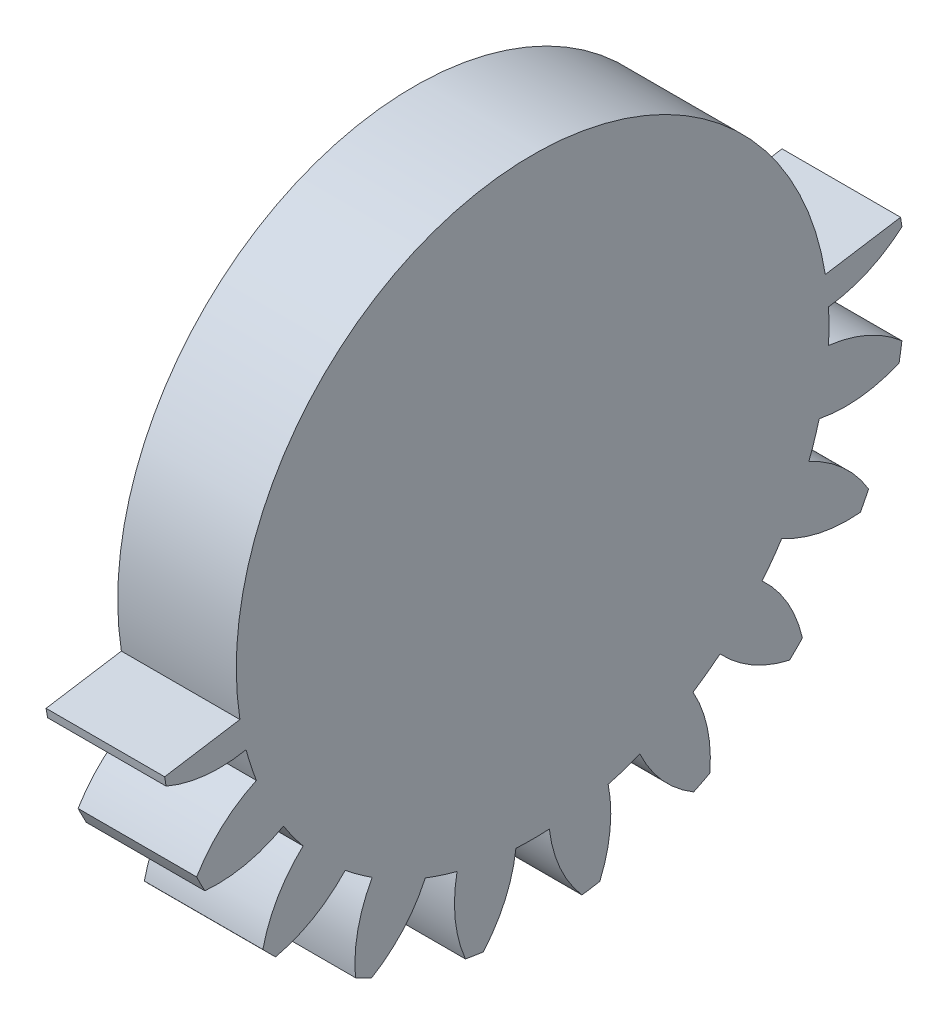
from build123d import *

# Parameters (mm, degrees)
BASPROSKE_W         = 15
BASPROSKE_H         = 22
TOOTHCUT_DEPTH      = 35.539832078
TEETHCUTS_COUNT     = 20
TEETHCUTS_ANGLE     = 342
BORSKE_R            = 0.5
BORE_DEPTH          = 50.0000508
SKETCH1_R           = 11.1
CUT_EXTRUDE1_DEPTH  = 16
CUT_EXTRUDE2_DEPTH  = 8
SKETCH3_R           = 11.1
BOSS_EXTRUDE1_DEPTH = 7
CUT_EXTRUDE3_DEPTH  = 7
SKETCH5_R           = 17.499
BOSS_EXTRUDE2_DEPTH = 7


with BuildPart() as part:
    # BasProSke → Base-Revolve (revolve)
    with BuildSketch(Plane(origin=(0, 0, 0), x_dir=(1, 0, 0), z_dir=(0, 1, 0)), mode=Mode.PRIVATE) as base_revolve_sk:
        with Locations((7.5, 11)):
            Rectangle(BASPROSKE_W, BASPROSKE_H)
    revolve(base_revolve_sk.sketch.rotate(Axis((-10, 0, 0), (1, 0, 0)), 180), axis=Axis((-10, 0, 0), (1, 0, 0)))

    # TooCutSke → ToothCut (cut, through all)
    with BuildSketch(Plane(origin=(0, 0, 0), x_dir=(0, 0, -1), z_dir=(1, 0, 0))):
        with BuildLine():
            ThreePointArc((0.986171591, 17.471189616), (0, 17.499), (-0.986171591, 17.471189616))
            ThreePointArc((-0.986171591, 17.471189616), (-1.626916196, 19.798789858), (-2.932850173, 21.829260982))
            ThreePointArc((-2.932850173, 21.829260982), (0, 22.0254), (2.932850173, 21.829260982))
            ThreePointArc((2.932850173, 21.829260982), (1.626916196, 19.798789858), (0.986171591, 17.471189616))
        make_face()
    toothcut = extrude(amount=TOOTHCUT_DEPTH, mode=Mode.SUBTRACT)

    # TeethCuts: ToothCut ×20 about axis
    teethcuts_axis = Axis((-10, 0, 0), (1, 0, 0))
    for i in range(1, TEETHCUTS_COUNT):
        add(toothcut.rotate(teethcuts_axis, i * TEETHCUTS_ANGLE / (TEETHCUTS_COUNT - 1)), mode=Mode.SUBTRACT)

    # BorSke → Bore (cut, symmetric)
    with BuildSketch(Plane(origin=(0, 0, 0), x_dir=(0, 0, -1), z_dir=(1, 0, 0))):
        with Locations(Location((0, 0, 0), (0, 0, 180))):
            Circle(BORSKE_R)
    extrude(amount=BORE_DEPTH, both=True, mode=Mode.SUBTRACT)

    # Sketch1 → Cut-Extrude1 (cut)
    with BuildSketch(Plane.ZY):
        Circle(SKETCH1_R)
    extrude(amount=-CUT_EXTRUDE1_DEPTH, mode=Mode.SUBTRACT)

    # Sketch2 → Cut-Extrude2 (cut)
    with BuildSketch(Plane.ZY):
        with BuildLine():
            ThreePointArc((17.471189616, 0.986171591), (19.784848102, 1.620704589), (21.806333941, 2.912696354))
            ThreePointArc((21.806333941, 2.912696354), (21.729143493, 3.441558231), (21.639128664, 3.968388926))
            ThreePointArc((21.639128664, 3.968388926), (19.317333972, 4.572472634), (16.920832513, 4.460989585))
            ThreePointArc((16.920832513, 4.460989585), (16.642537979, 5.407488385), (16.31134495, 6.336799421))
            ThreePointArc((16.31134495, 6.336799421), (18.31568345, 7.655235955), (19.838983319, 9.50866662))
            ThreePointArc((19.838983319, 9.50866662), (19.602143532, 9.987790994), (19.353734704, 10.461020648))
            ThreePointArc((19.353734704, 10.461020648), (16.958904602, 10.318064378), (14.714146429, 9.471478019))
            ThreePointArc((14.714146429, 9.471478019), (14.156988385, 10.28565413), (13.554832194, 11.067137173))
            ThreePointArc((13.554832194, 11.067137173), (15.05365209, 12.940419489), (15.929654782, 15.173862347))
            ThreePointArc((15.929654782, 15.173862347), (15.556349186, 15.556349186), (15.173862347, 15.929654782))
            ThreePointArc((15.173862347, 15.929654782), (12.940419489, 15.05365209), (11.067137173, 13.554832194))
            ThreePointArc((11.067137173, 13.554832194), (10.28565413, 14.156988385), (9.471478019, 14.714146429))
            ThreePointArc((9.471478019, 14.714146429), (10.318064378, 16.958904602), (10.461020648, 19.353734704))
            ThreePointArc((10.461020648, 19.353734704), (9.987790994, 19.602143532), (9.50866662, 19.838983319))
            ThreePointArc((9.50866662, 19.838983319), (7.655235955, 18.31568345), (6.336799421, 16.31134495))
            ThreePointArc((6.336799421, 16.31134495), (5.407488385, 16.642537979), (4.460989585, 16.920832513))
            ThreePointArc((4.460989585, 16.920832513), (4.572472634, 19.317333972), (3.968388926, 21.639128664))
            ThreePointArc((3.968388926, 21.639128664), (3.441558231, 21.729143493), (2.912696354, 21.806333941))
            ThreePointArc((2.912696354, 21.806333941), (1.620704589, 19.784848102), (0.986171591, 17.471189616))
            ThreePointArc((0.986171591, 17.471189616), (0, 17.499), (-0.986171591, 17.471189616))
            ThreePointArc((-0.986171591, 17.471189616), (-1.620704589, 19.784848102), (-2.912696354, 21.806333941))
            ThreePointArc((-2.912696354, 21.806333941), (-3.441558231, 21.729143493), (-3.968388926, 21.639128664))
            ThreePointArc((-3.968388926, 21.639128664), (-4.572472634, 19.317333972), (-4.460989585, 16.920832513))
            ThreePointArc((-4.460989585, 16.920832513), (-5.407488385, 16.642537979), (-6.336799421, 16.31134495))
            ThreePointArc((-6.336799421, 16.31134495), (-7.655235955, 18.31568345), (-9.50866662, 19.838983319))
            ThreePointArc((-9.50866662, 19.838983319), (-9.987790994, 19.602143532), (-10.461020648, 19.353734704))
            ThreePointArc((-10.461020648, 19.353734704), (-10.318064378, 16.958904602), (-9.471478019, 14.714146429))
            ThreePointArc((-9.471478019, 14.714146429), (-10.28565413, 14.156988385), (-11.067137173, 13.554832194))
            ThreePointArc((-11.067137173, 13.554832194), (-12.940419489, 15.05365209), (-15.173862347, 15.929654782))
            ThreePointArc((-15.173862347, 15.929654782), (-15.556349186, 15.556349186), (-15.929654782, 15.173862347))
            ThreePointArc((-15.929654782, 15.173862347), (-15.05365209, 12.940419489), (-13.554832194, 11.067137173))
            ThreePointArc((-13.554832194, 11.067137173), (-14.156988385, 10.28565413), (-14.714146429, 9.471478019))
            ThreePointArc((-14.714146429, 9.471478019), (-16.958904602, 10.318064378), (-19.353734704, 10.461020648))
            ThreePointArc((-19.353734704, 10.461020648), (-19.602143532, 9.987790994), (-19.838983319, 9.50866662))
            ThreePointArc((-19.838983319, 9.50866662), (-18.31568345, 7.655235955), (-16.31134495, 6.336799421))
            ThreePointArc((-16.31134495, 6.336799421), (-16.642537979, 5.407488385), (-16.920832513, 4.460989585))
            ThreePointArc((-16.920832513, 4.460989585), (-19.317333972, 4.572472634), (-21.639128664, 3.968388926))
            ThreePointArc((-21.639128664, 3.968388926), (-21.729143493, 3.441558231), (-21.806333941, 2.912696354))
            ThreePointArc((-21.806333941, 2.912696354), (-19.784848102, 1.620704589), (-17.471189616, 0.986171591))
            ThreePointArc((-17.471189616, 0.986171591), (-17.499, 0), (-17.471189616, -0.986171591))
            ThreePointArc((-17.471189616, -0.986171591), (-19.784848102, -1.620704589), (-21.806333941, -2.912696354))
            ThreePointArc((-21.806333941, -2.912696354), (-21.729143493, -3.441558231), (-21.639128664, -3.968388926))
            ThreePointArc((-21.639128664, -3.968388926), (-19.317333972, -4.572472634), (-16.920832513, -4.460989585))
            ThreePointArc((-16.920832513, -4.460989585), (-16.642537979, -5.407488385), (-16.31134495, -6.336799421))
            ThreePointArc((-16.31134495, -6.336799421), (-18.31568345, -7.655235955), (-19.838983319, -9.50866662))
            ThreePointArc((-19.838983319, -9.50866662), (-19.602143532, -9.987790994), (-19.353734704, -10.461020648))
            ThreePointArc((-19.353734704, -10.461020648), (-16.958904602, -10.318064378), (-14.714146429, -9.471478019))
            ThreePointArc((-14.714146429, -9.471478019), (-14.156988385, -10.28565413), (-13.554832194, -11.067137173))
            ThreePointArc((-13.554832194, -11.067137173), (-15.05365209, -12.940419489), (-15.929654782, -15.173862347))
            ThreePointArc((-15.929654782, -15.173862347), (-15.556349186, -15.556349186), (-15.173862347, -15.929654782))
            ThreePointArc((-15.173862347, -15.929654782), (-12.940419489, -15.05365209), (-11.067137173, -13.554832194))
            ThreePointArc((-11.067137173, -13.554832194), (-10.28565413, -14.156988385), (-9.471478019, -14.714146429))
            ThreePointArc((-9.471478019, -14.714146429), (-10.318064378, -16.958904602), (-10.461020648, -19.353734704))
            ThreePointArc((-10.461020648, -19.353734704), (-9.987790994, -19.602143532), (-9.50866662, -19.838983319))
            ThreePointArc((-9.50866662, -19.838983319), (-7.655235955, -18.31568345), (-6.336799421, -16.31134495))
            ThreePointArc((-6.336799421, -16.31134495), (-5.407488385, -16.642537979), (-4.460989585, -16.920832513))
            ThreePointArc((-4.460989585, -16.920832513), (-4.572472634, -19.317333972), (-3.968388926, -21.639128664))
            ThreePointArc((-3.968388926, -21.639128664), (-3.441558231, -21.729143493), (-2.912696354, -21.806333941))
            ThreePointArc((-2.912696354, -21.806333941), (-1.620704589, -19.784848102), (-0.986171591, -17.471189616))
            ThreePointArc((-0.986171591, -17.471189616), (0, -17.499), (0.986171591, -17.471189616))
            ThreePointArc((0.986171591, -17.471189616), (1.620704589, -19.784848102), (2.912696354, -21.806333941))
            ThreePointArc((2.912696354, -21.806333941), (3.441558231, -21.729143493), (3.968388926, -21.639128664))
            ThreePointArc((3.968388926, -21.639128664), (4.572472634, -19.317333972), (4.460989585, -16.920832513))
            ThreePointArc((4.460989585, -16.920832513), (5.407488385, -16.642537979), (6.336799421, -16.31134495))
            ThreePointArc((6.336799421, -16.31134495), (7.655235955, -18.31568345), (9.50866662, -19.838983319))
            ThreePointArc((9.50866662, -19.838983319), (9.987790994, -19.602143532), (10.461020648, -19.353734704))
            ThreePointArc((10.461020648, -19.353734704), (10.318064378, -16.958904602), (9.471478019, -14.714146429))
            ThreePointArc((9.471478019, -14.714146429), (10.28565413, -14.156988385), (11.067137173, -13.554832194))
            ThreePointArc((11.067137173, -13.554832194), (12.940419489, -15.05365209), (15.173862347, -15.929654782))
            ThreePointArc((15.173862347, -15.929654782), (15.556349186, -15.556349186), (15.929654782, -15.173862347))
            ThreePointArc((15.929654782, -15.173862347), (15.05365209, -12.940419489), (13.554832194, -11.067137173))
            ThreePointArc((13.554832194, -11.067137173), (14.156988385, -10.28565413), (14.714146429, -9.471478019))
            ThreePointArc((14.714146429, -9.471478019), (16.958904602, -10.318064378), (19.353734704, -10.461020648))
            ThreePointArc((19.353734704, -10.461020648), (19.602143532, -9.987790994), (19.838983319, -9.50866662))
            ThreePointArc((19.838983319, -9.50866662), (18.31568345, -7.655235955), (16.31134495, -6.336799421))
            ThreePointArc((16.31134495, -6.336799421), (16.642537979, -5.407488385), (16.920832513, -4.460989585))
            ThreePointArc((16.920832513, -4.460989585), (19.317333972, -4.572472634), (21.639128664, -3.968388926))
            ThreePointArc((21.639128664, -3.968388926), (21.729143493, -3.441558231), (21.806333941, -2.912696354))
            ThreePointArc((21.806333941, -2.912696354), (19.784848102, -1.620704589), (17.471189616, -0.986171591))
            ThreePointArc((17.471189616, -0.986171591), (17.499, 0), (17.471189616, 0.986171591))
        make_face()
    extrude(amount=-CUT_EXTRUDE2_DEPTH, mode=Mode.SUBTRACT)

    # Sketch3 → Boss-Extrude1 (add)
    with BuildSketch(Plane.ZY.offset(-8)):
        Circle(SKETCH3_R)
    extrude(amount=-BOSS_EXTRUDE1_DEPTH)

    # Sketch4 → Cut-Extrude3 (cut)
    with BuildSketch(Plane.ZY.offset(-8)):
        Polygon((21.729143493, -3.441558231), (0, 0), (-21.729143493, 3.441558231), (-17.979863548, 27.113580164), (25.478423438, 20.230463702), align=None)
    extrude(amount=-CUT_EXTRUDE3_DEPTH, mode=Mode.SUBTRACT)

    # Sketch5 → Boss-Extrude2 (add)
    with BuildSketch(Plane.ZY.offset(-8)):
        Circle(SKETCH5_R)
    extrude(amount=-BOSS_EXTRUDE2_DEPTH)


solid = part.part
